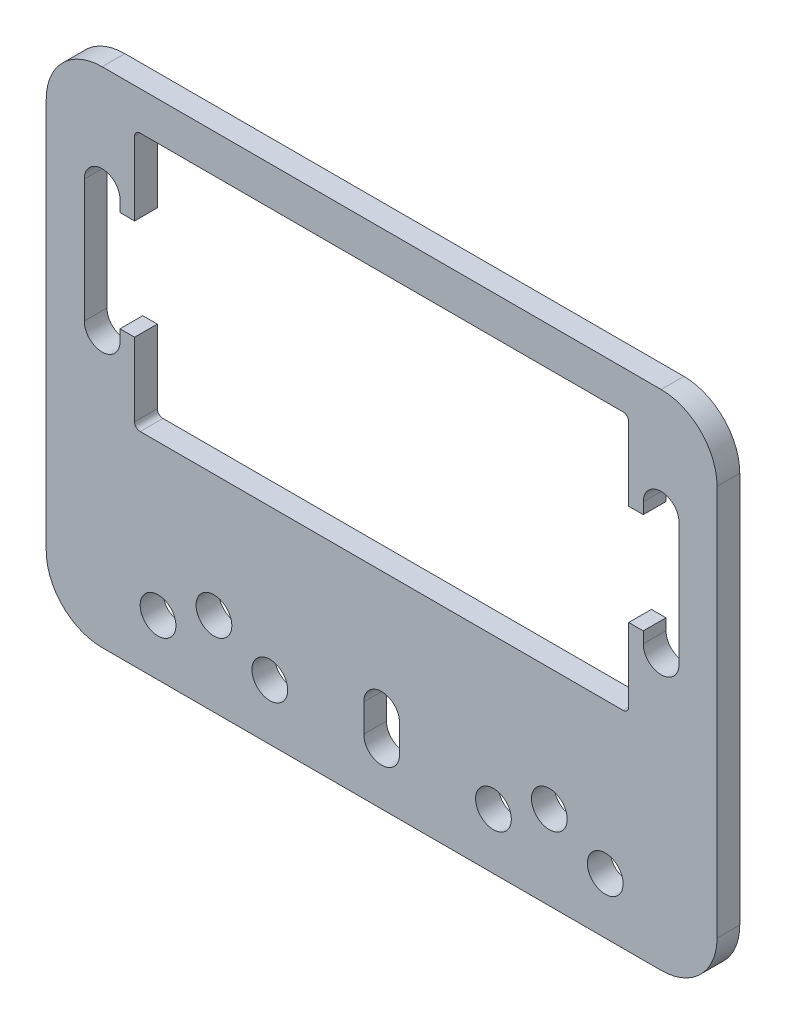
from build123d import *

# Parameters (mm, degrees)
SKETCH1_W           = 60
SKETCH1_H           = 45
BOSS_EXTRUDE1_DEPTH = 2.032
FILLET1_R           = 5
SKETCH2_W           = 44.196
SKETCH2_H           = 23.114
CUT_EXTRUDE1_DEPTH  = 3.032
FILLET2_R           = 0.5
CUT_EXTRUDE2_DEPTH  = 3.032
SKETCH4_R           = 1.6
CUT_EXTRUDE3_DEPTH  = 3.032


with BuildPart() as part:
    # Sketch1 → Boss-Extrude1 (new body)
    with BuildSketch(Plane.XY):
        Rectangle(SKETCH1_W, SKETCH1_H)
    extrude(amount=BOSS_EXTRUDE1_DEPTH)

    # Fillet1
    fillet1_edges = [part.edges().sort_by_distance(p)[0] for p in [
        (30, -22.5, 1.016),
        (-30, -22.5, 1.016),
        (-30, 22.5, 1.016),
        (30, 22.5, 1.016),
    ]]
    fillet(fillet1_edges, radius=FILLET1_R)

    # Sketch2 → Cut-Extrude1 (cut, through all)
    with BuildSketch(Plane.XY.offset(2.032)):
        with Locations((0, 7.5)):
            Rectangle(SKETCH2_W, SKETCH2_H)
    extrude(amount=-CUT_EXTRUDE1_DEPTH, mode=Mode.SUBTRACT)

    # Fillet2
    fillet2_edges = [part.edges().sort_by_distance(p)[0] for p in [
        (22.098, 19.057, 1.016),
        (22.098, -4.057, 1.016),
        (-22.098, -4.057, 1.016),
        (-22.098, 19.057, 1.016),
    ]]
    fillet(fillet2_edges, radius=FILLET2_R)

    # Sketch3 → Cut-Extrude2 (cut, through all)
    with BuildSketch(Plane.XY.offset(2.032)):
        with BuildLine():
            ThreePointArc((-26.6, 13), (-25, 14.6), (-23.4, 13))
            Line((-23.4, 13), (-23.4, 12))
            ThreePointArc((-23.4, 12), (-25, 10.4), (-26.6, 12))
            Line((-26.6, 12), (-26.6, 13))
        make_face()
        with BuildLine():
            ThreePointArc((-26.6, 3), (-25, 4.6), (-23.4, 3))
            Line((-23.4, 3), (-22.098, 3))
            Line((-22.098, 3), (-22.098, 12))
            Line((-22.098, 12), (-23.4, 12))
            ThreePointArc((-23.4, 12), (-25, 10.4), (-26.6, 12))
            Line((-26.6, 12), (-26.6, 3))
        make_face()
        with BuildLine():
            Line((-26.6, 3), (-26.6, 2))
            ThreePointArc((-26.6, 2), (-25, 0.4), (-23.4, 2))
            Line((-23.4, 2), (-23.4, 3))
            ThreePointArc((-23.4, 3), (-25, 4.6), (-26.6, 3))
        make_face()
        with BuildLine():
            ThreePointArc((26.6, 2), (25, 0.4), (23.4, 2))
            Line((23.4, 2), (23.4, 3))
            ThreePointArc((23.4, 3), (25, 4.6), (26.6, 3))
            Line((26.6, 3), (26.6, 2))
        make_face()
        with BuildLine():
            ThreePointArc((23.4, 12), (25, 10.4), (26.6, 12))
            Line((26.6, 12), (26.6, 3))
            ThreePointArc((26.6, 3), (25, 4.6), (23.4, 3))
            Line((23.4, 3), (20.842092025, 3))
            Line((20.842092025, 3), (20.842092025, 12))
            Line((20.842092025, 12), (23.4, 12))
        make_face()
        with BuildLine():
            Line((26.6, 12), (26.6, 13))
            ThreePointArc((26.6, 13), (25, 14.6), (23.4, 13))
            Line((23.4, 13), (23.4, 12))
            ThreePointArc((23.4, 12), (25, 10.4), (26.6, 12))
        make_face()
    extrude(amount=-CUT_EXTRUDE2_DEPTH, mode=Mode.SUBTRACT)

    # Sketch4 → Cut-Extrude3 (cut, through all)
    with BuildSketch(Plane.XY.offset(2.032)):
        with Locations((-15, -15)):
            Circle(SKETCH4_R)
        with Locations((15, -15)):
            Circle(SKETCH4_R)
        with Locations((10, -17.5)):
            Circle(SKETCH4_R)
        with Locations((-10, -17.5)):
            Circle(SKETCH4_R)
        with Locations((20, -17.5)):
            Circle(SKETCH4_R)
        with Locations((-20, -17.5)):
            Circle(SKETCH4_R)
        with BuildLine():
            Line((1.6, -15), (1.6, -17.5))
            ThreePointArc((1.6, -17.5), (0, -19.1), (-1.6, -17.5))
            Line((-1.6, -17.5), (-1.6, -15))
            ThreePointArc((-1.6, -15), (0, -13.4), (1.6, -15))
        make_face()
    extrude(amount=-CUT_EXTRUDE3_DEPTH, mode=Mode.SUBTRACT)


solid = part.part
